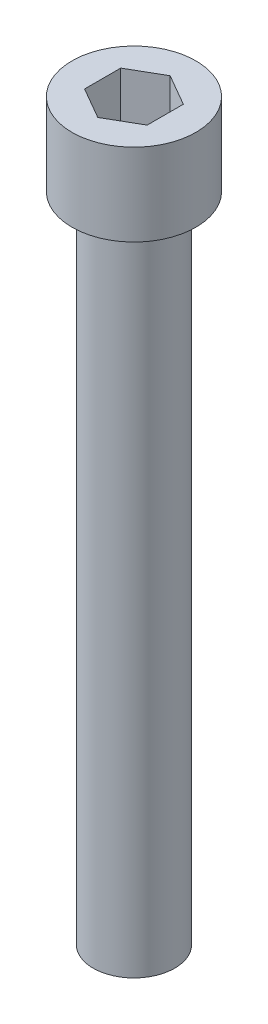
from build123d import *

# Parameters (mm, degrees)
SKETCH2_R           = 4.75
BOSS_EXTRUDE1_DEPTH = 6.3
SKETCH3_R           = 3.125
BOSS_EXTRUDE2_DEPTH = 50
CUT_EXTRUDE1_DEPTH  = 4.25


with BuildPart() as part:
    # Sketch2 → Boss-Extrude1 (new body)
    with BuildSketch(Plane(origin=(0, 0, 0), x_dir=(1, 0, 0), z_dir=(0, 1, 0))):
        Circle(SKETCH2_R)
    extrude(amount=BOSS_EXTRUDE1_DEPTH)

    # Sketch3 → Boss-Extrude2 (add)
    with BuildSketch(Plane.XZ):
        Circle(SKETCH3_R)
    extrude(amount=BOSS_EXTRUDE2_DEPTH)

    # Sketch4 → Cut-Extrude1 (cut)
    with BuildSketch(Plane(origin=(0, 6.3, 0), x_dir=(1, 0, 0), z_dir=(0, 1, 0))):
        Polygon((-2.4, 1.385640646), (-2.4, -1.385640646), (0, -2.771281292), (2.4, -1.385640646), (2.4, 1.385640646), (0, 2.771281292), align=None)
    extrude(amount=-CUT_EXTRUDE1_DEPTH, mode=Mode.SUBTRACT)


solid = part.part
